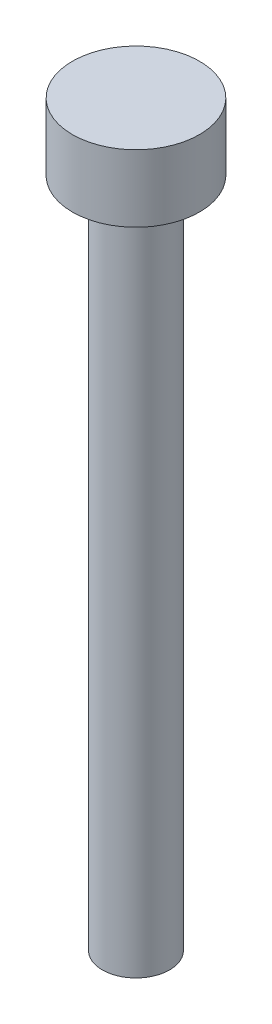
from build123d import *

# Parameters (mm, degrees)
CROQUIS1_R              = 1.5
SALIENTE_EXTRUIR1_DEPTH = 30
CROQUIS2_R              = 2.84
SALIENTE_EXTRUIR2_DEPTH = 3


with BuildPart() as part:
    # Croquis1 → Saliente-Extruir1 (new body)
    with BuildSketch(Plane(origin=(0, 0, 0), x_dir=(1, 0, 0), z_dir=(0, 1, 0))):
        Circle(CROQUIS1_R)
    extrude(amount=SALIENTE_EXTRUIR1_DEPTH)

    # Croquis2 → Saliente-Extruir2 (add)
    with BuildSketch(Plane(origin=(0, 30, 0), x_dir=(1, 0, 0), z_dir=(0, 1, 0))):
        Circle(CROQUIS2_R)
    extrude(amount=SALIENTE_EXTRUIR2_DEPTH)


solid = part.part
